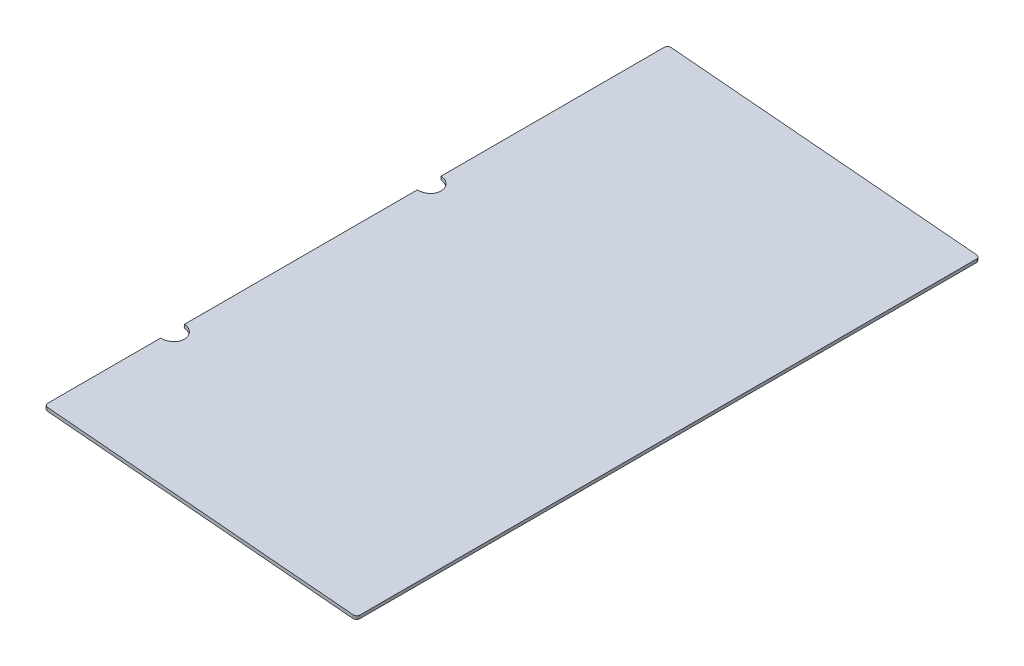
from build123d import *

# Parameters (mm, degrees)
BOSS_EXTRUDE1_DEPTH = 1168.4
SKETCH4_R           = 22.225
CUT_EXTRUDE1_DEPTH  = 58.348513463
FILLET1_R           = 6.35


with BuildPart() as part:
    # Sketch1 → Boss-Extrude1 (new body)
    with BuildSketch(Plane.XY):
        Polygon((22.225, 51.193319499), (607.367319431, 0), (607.920758397, 6.325836333), (22.778438966, 57.519155832), align=None)
    extrude(amount=BOSS_EXTRUDE1_DEPTH)

    # Sketch4 → Cut-Extrude1 (cut, through all)
    with BuildSketch(Plane(origin=(5.167076131, 59.05995043, 0), x_dir=(0.996194698, -0.087155743, 0), z_dir=(0.087155743, 0.996194698, 0))):
        with Locations((17.67863538, -446.88125)):
            Circle(SKETCH4_R)
        with Locations((17.67863538, -927.89375)):
            Circle(SKETCH4_R)
    extrude(amount=-CUT_EXTRUDE1_DEPTH, mode=Mode.SUBTRACT)

    # Fillet1
    fillet1_edges = [part.edges().sort_by_distance(p)[0] for p in [
        (607.644038914, 3.162918166, 1168.4),
        (22.501719483, 54.356237666, 1168.4),
        (607.644038914, 3.162918166, 0),
        (22.501719483, 54.356237666, 0),
    ]]
    fillet(fillet1_edges, radius=FILLET1_R)


solid = part.part
